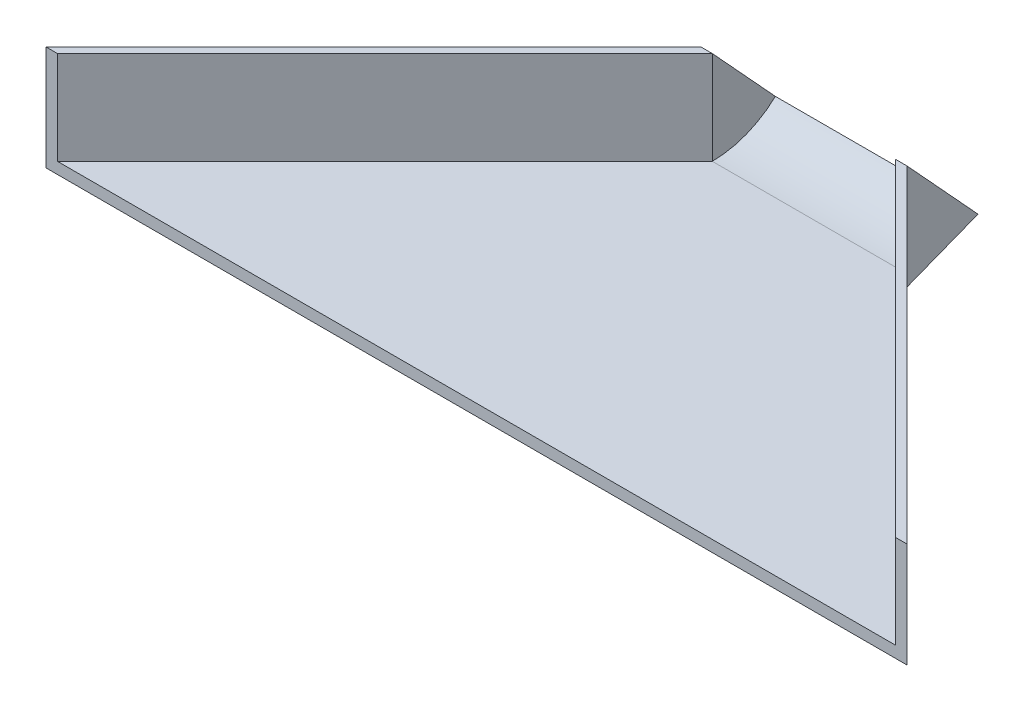
from build123d import *

# Parameters (mm, degrees)
BOSS_EXTRUDE1_DEPTH   = 2.7686
BOSS_EXTRUDE2_START   = -2.7686
BOSS_EXTRUDE2_DEPTH   = 25.4
BOSS_EXTRUDE2_2_DEPTH = 25.4
SKETCH4_W             = 2.7686
SKETCH4_H             = 25.4
BOSS_EXTRUDE3_DEPTH   = 25.4
CUT_EXTRUDE1_DEPTH    = 2.7686
BOSS_EXTRUDE6_DEPTH   = 44.45
BOSS_EXTRUDE7_DEPTH   = 2.7686


with BuildPart() as part:
    # Sketch1 → Boss-Extrude1 (new body)
    with BuildSketch(Plane(origin=(0, 0, 0), x_dir=(1, 0, 0), z_dir=(0, 1, 0))):
        Polygon((0, 0), (44.45, 0), (123.825, -79.375), (-79.375, -79.375), align=None)
    extrude(amount=BOSS_EXTRUDE1_DEPTH)



with BuildPart() as body_2:
    # Sketch2 → Boss-Extrude2 (new body)
    with BuildSketch(Plane(origin=(0, 2.7686, 0), x_dir=(1, 0, 0), z_dir=(0, 1, 0)).offset(BOSS_EXTRUDE2_START)):
        Polygon((0, 0), (-79.375, -79.375), (-82.1436, -79.375), (-2.7686, 0), align=None)
    extrude(amount=BOSS_EXTRUDE2_DEPTH)


with BuildPart() as body_3:
    # Sketch2 → Boss-Extrude2 2 (new body)
    with BuildSketch(Plane(origin=(0, 2.7686, 0), x_dir=(1, 0, 0), z_dir=(0, 1, 0)).offset(BOSS_EXTRUDE2_START)):
        Polygon((44.45, 0), (47.2186, 0), (126.5936, -79.375), (123.825, -79.375), align=None)
    extrude(amount=BOSS_EXTRUDE2_2_DEPTH)


with BuildPart() as part_1:
    add(part.part)

    add(body_3.part)  # Boss-Extrude3 merges body 3
    # Sketch4 → Boss-Extrude3 (add)
    with BuildSketch(Plane(origin=(0, 0, 0), x_dir=(-1, 0, 0), z_dir=(0, 0, -1))):
        with Locations((-45.8343, 12.7)):
            Rectangle(SKETCH4_W, SKETCH4_H)
    extrude(amount=BOSS_EXTRUDE3_DEPTH)

    # Sketch5 → Cut-Extrude1 (cut)
    with BuildSketch(Plane(origin=(47.2186, 0, 0), x_dir=(0, 0, -1), z_dir=(1, 0, 0))):
        Polygon((17.186035514, 6.697089394), (0, 0), (25.4, 0), (25.4, 14.244871038), (25.4, 25.4), (0, 25.4), align=None)
    extrude(amount=-CUT_EXTRUDE1_DEPTH, mode=Mode.SUBTRACT)


    add(body_2.part)  # Boss-Extrude6 merges body 2
    # Sketch10 → Boss-Extrude6 (add)
    with BuildSketch(Plane.ZY.offset(-44.45)):
        with BuildLine():
            Line((-17.186035514, 6.697089394), (-15.298135688, 8.75161917))
            ThreePointArc((-15.298135688, 8.75161917), (-8.213243481, 4.317554379), (0, 2.7686))
            Line((0, 2.7686), (0, 0))
            Line((0, 0), (-17.186035514, 6.697089394))
        make_face()
    extrude(amount=BOSS_EXTRUDE6_DEPTH)

    # Sketch11 → Boss-Extrude7 (add)
    with BuildSketch(Plane.ZY):
        Polygon((0, 0), (0, 25.4), (-17.186035514, 6.697089394), align=None)
    extrude(amount=BOSS_EXTRUDE7_DEPTH)


solid = part_1.part
